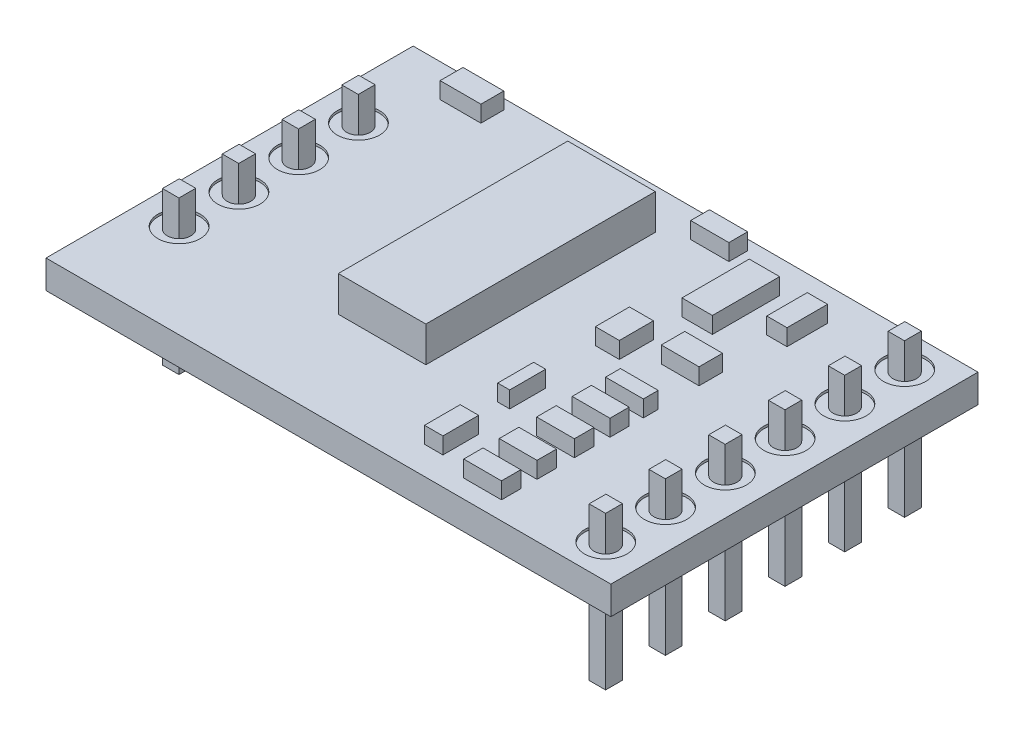
from build123d import *

# Parameters (mm, degrees)
SKETCH1_W                   = 24
SKETCH1_H                   = 15.6
BOSS_EXTRUDE1_DEPTH         = 1.2
SKETCH3_W                   = 3.718844476
SKETCH3_H                   = 9.7472871
BOSS_EXTRUDE2_DEPTH         = 1.5
SKETCH4_W                   = 1.291809133
SKETCH4_H                   = 2.857638387
SKETCH4_W_2                 = 0.861206089
SKETCH4_H_2                 = 1.722412179
SKETCH4_W_3                 = 1.017789015
SKETCH4_H_3                 = 1.448392059
SKETCH4_W_4                 = 1.604974985
SKETCH4_H_4                 = 0.998216149
SKETCH4_W_5                 = 0.508894507
SKETCH4_H_5                 = 1.526683522
SKETCH4_H_6                 = 0.632206169
SKETCH4_H_7                 = 0.817242122
SKETCH4_H_8                 = 0.832661784
SKETCH4_H_9                 = 0.819418919
SKETCH4_W_6                 = 0.782914627
SKETCH4_H_10                = 1.516221838
SKETCH4_W_7                 = 1.623006581
SKETCH4_H_11                = 0.796748686
SKETCH4_W_8                 = 1.733725138
SKETCH4_H_12                = 0.971445752
BOSS_EXTRUDE3_DEPTH         = 0.7
SKETCH5_R                   = 0.5
CUT_EXTRUDE1_DEPTH          = 2.2
SKETCH6_R                   = 0.9
CUT_EXTRUDE2_DEPTH          = 0.1
SKETCH7_R                   = 0.9
CUT_EXTRUDE3_DEPTH          = 0.1
SKETCH8_W                   = 0.7
SKETCH8_H                   = 0.714142842
BOSS_EXTRUDE5_DEPTH         = 1.5
BOSS_EXTRUDE5_DEPTH_BACK    = 5
BOSS_EXTRUDE5_2_DEPTH       = 1.5
BOSS_EXTRUDE5_2_DEPTH_BACK  = 5
BOSS_EXTRUDE5_3_DEPTH       = 1.5
BOSS_EXTRUDE5_3_DEPTH_BACK  = 5
BOSS_EXTRUDE5_4_DEPTH       = 1.5
BOSS_EXTRUDE5_4_DEPTH_BACK  = 5
BOSS_EXTRUDE5_5_DEPTH       = 1.5
BOSS_EXTRUDE5_5_DEPTH_BACK  = 5
BOSS_EXTRUDE5_6_DEPTH       = 1.5
BOSS_EXTRUDE5_6_DEPTH_BACK  = 5
BOSS_EXTRUDE5_7_DEPTH       = 1.5
BOSS_EXTRUDE5_7_DEPTH_BACK  = 5
BOSS_EXTRUDE5_8_DEPTH       = 1.5
BOSS_EXTRUDE5_8_DEPTH_BACK  = 5
BOSS_EXTRUDE5_9_DEPTH       = 1.5
BOSS_EXTRUDE5_9_DEPTH_BACK  = 5
BOSS_EXTRUDE5_10_DEPTH      = 1.5
BOSS_EXTRUDE5_10_DEPTH_BACK = 5


with BuildPart() as part:
    # Sketch1 → Boss-Extrude1 (new body)
    with BuildSketch(Plane(origin=(0, 0, 0), x_dir=(1, 0, 0), z_dir=(0, 1, 0))):
        Rectangle(SKETCH1_W, SKETCH1_H)
    extrude(amount=BOSS_EXTRUDE1_DEPTH)

    # Sketch3 → Boss-Extrude2 (add)
    with BuildSketch(Plane(origin=(0, 1.2, 0), x_dir=(1, 0, 0), z_dir=(0, 1, 0))):
        with Locations((-1.859422238, 1.213517671)):
            Rectangle(SKETCH3_W, SKETCH3_H)
    extrude(amount=BOSS_EXTRUDE2_DEPTH)

    # Sketch4 → Boss-Extrude3 (add)
    with BuildSketch(Plane(origin=(0, 1.2, 0), x_dir=(1, 0, 0), z_dir=(0, 1, 0))):
        with Locations((4.325603312, 4.971507879)):
            Rectangle(SKETCH4_W, SKETCH4_H)
        with Locations((6.576482863, 5.539120983)):
            Rectangle(SKETCH4_W_2, SKETCH4_H_2)
        with Locations((3.405678626, 1.370100597)):
            Rectangle(SKETCH4_W_3, SKETCH4_H_3)
        with Locations((5.773995371, 1.86920867)):
            Rectangle(SKETCH4_W_4, SKETCH4_H_4)
        with Locations((3.151231372, -2.740201193)):
            Rectangle(SKETCH4_W_5, SKETCH4_H_5)
        with Locations((5.773995371, -0.680264503)):
            Rectangle(SKETCH4_W_4, SKETCH4_H_6)
        with Locations((5.773995371, -2.006355492)):
            Rectangle(SKETCH4_W_4, SKETCH4_H_7)
        with Locations((5.773995371, -3.509772602)):
            Rectangle(SKETCH4_W_4, SKETCH4_H_8)
        with Locations((5.773995371, -5.097997857)):
            Rectangle(SKETCH4_W_4, SKETCH4_H_8)
        with Locations((5.773995371, -6.614219696)):
            Rectangle(SKETCH4_W_4, SKETCH4_H_9)
        with Locations((3.288241432, -5.856108776)):
            Rectangle(SKETCH4_W_6, SKETCH4_H_10)
        with Locations((1.82829659, 6.973398481)):
            Rectangle(SKETCH4_W_7, SKETCH4_H_11)
        with Locations((-8.587746515, 6.886049948)):
            Rectangle(SKETCH4_W_8, SKETCH4_H_12)
    extrude(amount=BOSS_EXTRUDE3_DEPTH)

    # Sketch5 → Cut-Extrude1 (cut, through all)
    with BuildSketch(Plane(origin=(0, 1.2, 0), x_dir=(1, 0, 0), z_dir=(0, 1, 0))):
        with Locations((-10.33447307, 3.81)):
            Circle(SKETCH5_R)
        with Locations((-10.33447307, 1.27)):
            Circle(SKETCH5_R)
        with Locations((-10.33447307, -1.27)):
            Circle(SKETCH5_R)
        with Locations((-10.33447307, -3.81)):
            Circle(SKETCH5_R)
        with Locations((10.33447307, -3.81)):
            Circle(SKETCH5_R)
        with Locations((10.33447307, -1.27)):
            Circle(SKETCH5_R)
        with Locations((10.33447307, 1.27)):
            Circle(SKETCH5_R)
        with Locations((10.33447307, 3.81)):
            Circle(SKETCH5_R)
        with Locations((10.33447307, 6.35)):
            Circle(SKETCH5_R)
        with Locations((10.33447307, -6.35)):
            Circle(SKETCH5_R)
    extrude(amount=-CUT_EXTRUDE1_DEPTH, mode=Mode.SUBTRACT)

    # Sketch6 → Cut-Extrude2 (cut)
    with BuildSketch(Plane(origin=(0, 1.2, 0), x_dir=(1, 0, 0), z_dir=(0, 1, 0))):
        with Locations((-10.33447307, 3.81)):
            Circle(SKETCH6_R)
        with Locations((-10.33447307, 1.27)):
            Circle(SKETCH6_R)
        with Locations((-10.33447307, -1.27)):
            Circle(SKETCH6_R)
        with Locations((-10.33447307, -3.81)):
            Circle(SKETCH6_R)
    extrude(amount=-CUT_EXTRUDE2_DEPTH, mode=Mode.SUBTRACT)

    # Sketch7 → Cut-Extrude3 (cut)
    with BuildSketch(Plane(origin=(0, 1.2, 0), x_dir=(1, 0, 0), z_dir=(0, 1, 0))):
        with Locations((10.33447307, 6.35)):
            Circle(SKETCH7_R)
        with Locations((10.33447307, 3.81)):
            Circle(SKETCH7_R)
        with Locations((10.33447307, 1.27)):
            Circle(SKETCH7_R)
        with Locations((10.33447307, -1.27)):
            Circle(SKETCH7_R)
        with Locations((10.33447307, -3.81)):
            Circle(SKETCH7_R)
        with Locations((10.33447307, -6.35)):
            Circle(SKETCH7_R)
    extrude(amount=-CUT_EXTRUDE3_DEPTH, mode=Mode.SUBTRACT)


with BuildPart() as body_2:
    # Sketch8 → Boss-Extrude5 (new body, two sides)
    with BuildSketch(Plane(origin=(0, 1.1, 0), x_dir=(1, 0, 0), z_dir=(0, 1, 0))) as boss_extrude5_sk:
        with Locations((-10.33447307, 1.27)):
            Rectangle(SKETCH8_W, SKETCH8_H)
    extrude(amount=BOSS_EXTRUDE5_DEPTH)
    extrude(boss_extrude5_sk.sketch, amount=-BOSS_EXTRUDE5_DEPTH_BACK)


with BuildPart() as body_3:
    # Sketch8 → Boss-Extrude5 2 (new body, two sides)
    with BuildSketch(Plane(origin=(0, 1.1, 0), x_dir=(1, 0, 0), z_dir=(0, 1, 0))) as boss_extrude5_2_sk:
        with Locations((-10.33447307, 3.81)):
            Rectangle(SKETCH8_W, SKETCH8_H)
    extrude(amount=BOSS_EXTRUDE5_2_DEPTH)
    extrude(boss_extrude5_2_sk.sketch, amount=-BOSS_EXTRUDE5_2_DEPTH_BACK)


with BuildPart() as body_4:
    # Sketch8 → Boss-Extrude5 3 (new body, two sides)
    with BuildSketch(Plane(origin=(0, 1.1, 0), x_dir=(1, 0, 0), z_dir=(0, 1, 0))) as boss_extrude5_3_sk:
        with Locations((-10.33447307, -1.27)):
            Rectangle(SKETCH8_W, SKETCH8_H)
    extrude(amount=BOSS_EXTRUDE5_3_DEPTH)
    extrude(boss_extrude5_3_sk.sketch, amount=-BOSS_EXTRUDE5_3_DEPTH_BACK)


with BuildPart() as body_5:
    # Sketch8 → Boss-Extrude5 4 (new body, two sides)
    with BuildSketch(Plane(origin=(0, 1.1, 0), x_dir=(1, 0, 0), z_dir=(0, 1, 0))) as boss_extrude5_4_sk:
        with Locations((-10.33447307, -3.81)):
            Rectangle(SKETCH8_W, SKETCH8_H)
    extrude(amount=BOSS_EXTRUDE5_4_DEPTH)
    extrude(boss_extrude5_4_sk.sketch, amount=-BOSS_EXTRUDE5_4_DEPTH_BACK)


with BuildPart() as body_6:
    # Sketch8 → Boss-Extrude5 5 (new body, two sides)
    with BuildSketch(Plane(origin=(0, 1.1, 0), x_dir=(1, 0, 0), z_dir=(0, 1, 0))) as boss_extrude5_5_sk:
        with Locations((10.33447307, -3.81)):
            Rectangle(SKETCH8_W, SKETCH8_H)
    extrude(amount=BOSS_EXTRUDE5_5_DEPTH)
    extrude(boss_extrude5_5_sk.sketch, amount=-BOSS_EXTRUDE5_5_DEPTH_BACK)


with BuildPart() as body_7:
    # Sketch8 → Boss-Extrude5 6 (new body, two sides)
    with BuildSketch(Plane(origin=(0, 1.1, 0), x_dir=(1, 0, 0), z_dir=(0, 1, 0))) as boss_extrude5_6_sk:
        with Locations((10.33447307, -1.27)):
            Rectangle(SKETCH8_W, SKETCH8_H)
    extrude(amount=BOSS_EXTRUDE5_6_DEPTH)
    extrude(boss_extrude5_6_sk.sketch, amount=-BOSS_EXTRUDE5_6_DEPTH_BACK)


with BuildPart() as body_8:
    # Sketch8 → Boss-Extrude5 7 (new body, two sides)
    with BuildSketch(Plane(origin=(0, 1.1, 0), x_dir=(1, 0, 0), z_dir=(0, 1, 0))) as boss_extrude5_7_sk:
        with Locations((10.33447307, 1.27)):
            Rectangle(SKETCH8_W, SKETCH8_H)
    extrude(amount=BOSS_EXTRUDE5_7_DEPTH)
    extrude(boss_extrude5_7_sk.sketch, amount=-BOSS_EXTRUDE5_7_DEPTH_BACK)


with BuildPart() as body_9:
    # Sketch8 → Boss-Extrude5 8 (new body, two sides)
    with BuildSketch(Plane(origin=(0, 1.1, 0), x_dir=(1, 0, 0), z_dir=(0, 1, 0))) as boss_extrude5_8_sk:
        with Locations((10.33447307, 3.81)):
            Rectangle(SKETCH8_W, SKETCH8_H)
    extrude(amount=BOSS_EXTRUDE5_8_DEPTH)
    extrude(boss_extrude5_8_sk.sketch, amount=-BOSS_EXTRUDE5_8_DEPTH_BACK)


with BuildPart() as body_10:
    # Sketch8 → Boss-Extrude5 9 (new body, two sides)
    with BuildSketch(Plane(origin=(0, 1.1, 0), x_dir=(1, 0, 0), z_dir=(0, 1, 0))) as boss_extrude5_9_sk:
        with Locations((10.33447307, 6.35)):
            Rectangle(SKETCH8_W, SKETCH8_H)
    extrude(amount=BOSS_EXTRUDE5_9_DEPTH)
    extrude(boss_extrude5_9_sk.sketch, amount=-BOSS_EXTRUDE5_9_DEPTH_BACK)


with BuildPart() as body_11:
    # Sketch8 → Boss-Extrude5 10 (new body, two sides)
    with BuildSketch(Plane(origin=(0, 1.1, 0), x_dir=(1, 0, 0), z_dir=(0, 1, 0))) as boss_extrude5_10_sk:
        with Locations((10.33447307, -6.35)):
            Rectangle(SKETCH8_W, SKETCH8_H)
    extrude(amount=BOSS_EXTRUDE5_10_DEPTH)
    extrude(boss_extrude5_10_sk.sketch, amount=-BOSS_EXTRUDE5_10_DEPTH_BACK)


solid = Compound([part.part, body_2.part, body_3.part, body_4.part, body_5.part, body_6.part, body_7.part, body_8.part, body_9.part, body_10.part, body_11.part])
